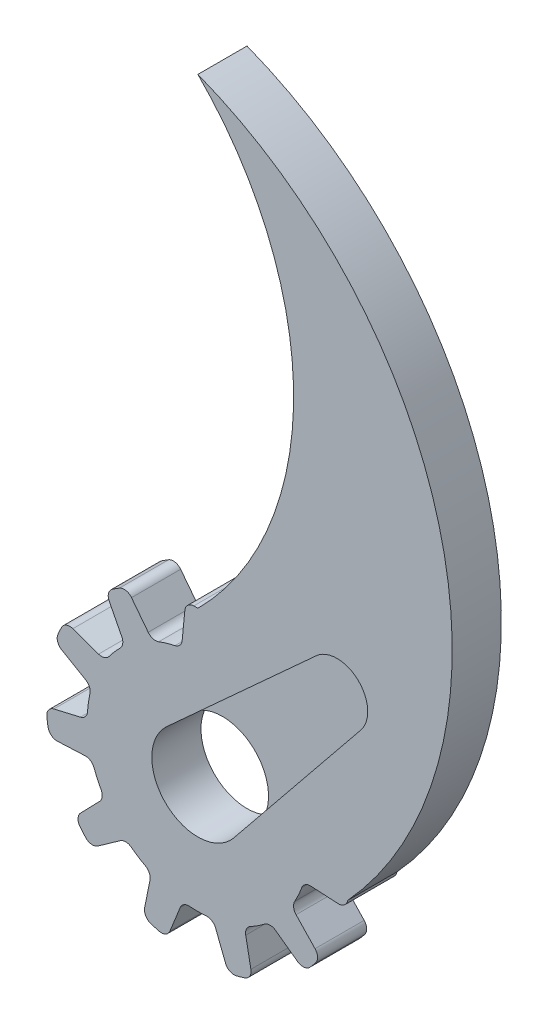
from build123d import *

# Parameters (mm, degrees)
ESBO_O1_R                = 3.75
RESSALTO_EXTRUS_O1_DEPTH = 4
RESSALTO_EXTRUS_O2_START = -4
RESSALTO_EXTRUS_O2_DEPTH = 4
CORTE_EXTRUS_O1_START    = -2
CORTE_EXTRUS_O1_DEPTH    = 2


with BuildPart() as part:
    # Esboço1 → Ressalto-extrusão1 (new body)
    with BuildSketch(Plane.XY):
        with BuildLine():
            Line((5.428931338, 10.411256864), (4.040153116, 8.653603149))
            ThreePointArc((4.040153116, 8.653603149), (3.651813796, 8.395770502), (3.186165661, 8.417146095))
            ThreePointArc((3.186165661, 8.417146095), (2.535977815, 8.635323765), (1.871064211, 8.803358377))
            ThreePointArc((1.871064211, 8.803358377), (1.465141223, 9.040151498), (1.27980553, 9.472002324))
            Line((1.27980553, 9.472002324), (1.087391415, 11.684866251))
            ThreePointArc((1.087391415, 11.684866251), (0.855086446, 12.165243662), (0.362160028, 12.369575749))
            ThreePointArc((0.362160028, 12.369575749), (0.013315066, 12.374869163), (-0.335540479, 12.370326458))
            ThreePointArc((-0.335540479, 12.370326458), (-0.826548297, 12.16926195), (-1.061642754, 11.693608494))
            Line((-1.061642754, 11.693608494), (-1.279697998, 9.464145904))
            ThreePointArc((-1.279697998, 9.464145904), (-1.466994971, 9.037291191), (-1.870279627, 8.803525096))
            ThreePointArc((-1.870279627, 8.803525096), (-2.535208203, 8.635549743), (-3.185415492, 8.41743002))
            ThreePointArc((-3.185415492, 8.41743002), (-3.654919666, 8.397174533), (-4.044310156, 8.660270526))
            Line((-4.044310156, 8.660270526), (-5.402543773, 10.417823198))
            ThreePointArc((-5.402543773, 10.417823198), (-5.857682784, 10.696348844), (-6.382829142, 10.601747792))
            ThreePointArc((-6.382829142, 10.601747792), (-6.679158034, 10.41760107), (-6.970178022, 10.225173956))
            ThreePointArc((-6.970178022, 10.225173956), (-7.274536404, 9.790568861), (-7.215152773, 9.263322051))
            Line((-7.215152773, 9.263322051), (-6.19325404, 7.269889205))
            ThreePointArc((-6.19325404, 7.269889205), (-6.120043199, 6.809535782), (-6.332924348, 6.394847082))
            ThreePointArc((-6.332924348, 6.394847082), (-6.80148353, 5.894049694), (-7.230548283, 5.359027107))
            ThreePointArc((-7.230548283, 5.359027107), (-7.614569385, 5.088153986), (-8.084385943, 5.098964027))
            Line((-8.084385943, 5.098964027), (-10.177209485, 5.843194888))
            ThreePointArc((-10.177209485, 5.843194888), (-10.710679119, 5.831438844), (-11.101315158, 5.46793982))
            ThreePointArc((-11.101315158, 5.46793982), (-11.251045651, 5.152818244), (-11.391833292, 4.833600971))
            ThreePointArc((-11.391833292, 4.833600971), (-11.412910602, 4.303439334), (-11.077902766, 3.891996308))
            Line((-11.077902766, 3.891996308), (-9.140495683, 2.76749405))
            ThreePointArc((-9.140495683, 2.76749405), (-8.830020954, 2.419800875), (-8.784910335, 1.955850303))
            ThreePointArc((-8.784910335, 1.955850303), (-8.908335893, 1.281230512), (-8.980033083, 0.599170952))
            ThreePointArc((-8.980033083, 0.599170952), (-9.156647127, 0.163680499), (-9.557726315, -0.081227523))
            Line((-9.557726315, -0.081227523), (-11.720683094, -0.586606513))
            ThreePointArc((-11.720683094, -0.586606513), (-12.163110512, -0.884911785), (-12.295212049, -1.401900411))
            ThreePointArc((-12.295212049, -1.401900411), (-12.25080577, -1.747947966), (-12.196661982, -2.09260617))
            ThreePointArc((-12.196661982, -2.09260617), (-11.927766323, -2.550001774), (-11.423496904, -2.715010763))
            Line((-11.423496904, -2.715010763), (-9.185694531, -2.613560912))
            ThreePointArc((-9.185694531, -2.613560912), (-8.736529446, -2.738203711), (-8.447749362, -3.104115127))
            ThreePointArc((-8.447749362, -3.104115127), (-8.186854553, -3.738370305), (-7.878420829, -4.350917747))
            ThreePointArc((-7.878420829, -4.350917747), (-7.791554103, -4.812760389), (-7.996556113, -5.235629909))
            Line((-7.996556113, -5.235629909), (-9.542922635, -6.83016449))
            ThreePointArc((-9.542922635, -6.83016449), (-9.753840257, -7.320309176), (-9.585465989, -7.826647167))
            ThreePointArc((-9.585465989, -7.826647167), (-9.361021617, -8.093753047), (-9.129136671, -8.354425638))
            ThreePointArc((-9.129136671, -8.354425638), (-8.655640515, -8.593835336), (-8.142211489, -8.4600211))
            Line((-8.142211489, -8.4600211), (-6.314500268, -7.16482875))
            ThreePointArc((-6.314500268, -7.16482875), (-5.869251568, -7.026847967), (-5.428487655, -7.178545938))
            ThreePointArc((-5.428487655, -7.178545938), (-4.866104738, -7.571064963), (-4.275465628, -7.919620803))
            ThreePointArc((-4.275465628, -7.919620803), (-3.952697704, -8.26118386), (-3.896535847, -8.727756791))
            Line((-3.896535847, -8.727756791), (-4.335351667, -10.905193502))
            ThreePointArc((-4.335351667, -10.905193502), (-4.247794638, -11.431560125), (-3.832402205, -11.766488747))
            ThreePointArc((-3.832402205, -11.766488747), (-3.499179242, -11.869848724), (-3.16317497, -11.963773995))
            ThreePointArc((-3.16317497, -11.963773995), (-2.635410001, -11.909186901), (-2.275831457, -11.519034514))
            Line((-2.275831457, -11.519034514), (-1.438496786, -9.441314085))
            ThreePointArc((-1.438496786, -9.441314085), (-1.138527788, -9.084517642), (-0.685719474, -8.973839134))
            ThreePointArc((-0.685719474, -8.973839134), (-0.000401051, -8.999999991), (0.684919701, -8.973900211))
            ThreePointArc((0.684919701, -8.973900211), (1.141112287, -9.086739826), (1.440607019, -9.44888256))
            Line((1.440607019, -9.44888256), (2.248662823, -11.517900629))
            ThreePointArc((2.248662823, -11.517900629), (2.606895765, -11.913371507), (3.137422201, -11.970553289))
            ThreePointArc((3.137422201, -11.970553289), (3.473627818, -11.877351299), (3.807072434, -11.774708641))
            ThreePointArc((3.807072434, -11.774708641), (4.221544568, -11.44345577), (4.313108983, -10.920835859))
            Line((4.313108983, -10.920835859), (3.894219261, -8.720248907))
            ThreePointArc((3.894219261, -8.720248907), (3.953670521, -8.257917155), (4.274759795, -7.920001811))
            ThreePointArc((4.274759795, -7.920001811), (4.865429967, -7.571498612), (5.427847864, -7.179029709))
            ThreePointArc((5.427847864, -7.179029709), (5.87262719, -7.0273201), (6.320367336, -7.170054878))
            Line((6.320367336, -7.170054878), (8.118742756, -8.473755688))
            ThreePointArc((8.118742756, -8.473755688), (8.633915182, -8.612771611), (9.111137226, -8.374051741))
            ThreePointArc((9.111137226, -8.374051741), (9.343582589, -8.113878758), (9.56860124, -7.847256489))
            ThreePointArc((9.56860124, -7.847256489), (9.738188564, -7.344508289), (9.532667795, -6.855348982))
            Line((9.532667795, -6.855348982), (7.990548209, -5.230566315))
            ThreePointArc((7.990548209, -5.230566315), (7.790606374, -4.809486318), (7.878033033, -4.351619874))
            ThreePointArc((7.878033033, -4.351619874), (8.186521347, -3.739099922), (8.447472682, -3.104867999))
            ThreePointArc((8.447472682, -3.104867999), (8.739624454, -2.736775896), (9.19345568, -2.614785434))
            Line((9.19345568, -2.614785434), (11.411179228, -2.739253189))
            ThreePointArc((11.411179228, -2.739253189), (11.919727533, -2.577677583), (12.192130558, -2.118847933))
            ThreePointArc((12.192130558, -2.118847933), (12.247015907, -1.774307042), (12.292166761, -1.428355848))
            ThreePointArc((12.292166761, -1.428355848), (12.163026498, -0.913731319), (11.725671937, -0.61333724))
            Line((11.725671937, -0.61333724), (9.549934558, -0.080215876))
            ThreePointArc((9.549934558, -0.080215876), (9.15407975, 0.165922443), (8.980086447, 0.598370627))
            ThreePointArc((8.980086447, 0.598370627), (8.908450044, 1.280436574), (8.78508461, 1.955067363))
            ThreePointArc((8.78508461, 1.955067363), (8.831852706, 2.422675318), (9.147686805, 2.77065991))
            Line((9.147686805, 2.77065991), (11.080646922, 3.864942843))
            ThreePointArc((11.080646922, 3.864942843), (11.421110614, 4.275810864), (11.402208583, 4.809075122))
            ThreePointArc((11.402208583, 4.809075122), (11.262108208, 5.128594624), (11.113056187, 5.444037682))
            ThreePointArc((11.113056187, 5.444037682), (10.726189458, 5.807148888), (10.195858089, 5.823404741))
            Line((10.195858089, 5.823404741), (8.077284162, 5.095602537))
            ThreePointArc((8.077284162, 5.095602537), (7.611197484, 5.088652), (7.231025864, 5.358382681))
            ThreePointArc((7.231025864, 5.358382681), (6.802008795, 5.893443506), (6.333494247, 6.394282651))
            ThreePointArc((6.333494247, 6.394282651), (6.120030126, 6.812944237), (6.197592003, 7.27644031))
            Line((6.197592003, 7.27644031), (7.232087511, 9.242046831))
            ThreePointArc((7.232087511, 9.242046831), (7.296371772, 9.771759573), (6.992165948, 10.210150805))
            ThreePointArc((6.992165948, 10.210150805), (6.701560727, 10.403203734), (6.405628795, 10.587987714))
            ThreePointArc((6.405628795, 10.587987714), (5.883863054, 10.684300355), (5.428931338, 10.411256864))
        make_face()
        Circle(ESBO_O1_R, mode=Mode.SUBTRACT)
    extrude(amount=RESSALTO_EXTRUS_O1_DEPTH)

    # Esboço6 → Ressalto-extrusão2 (add)
    with BuildSketch(Plane.XY.offset(4).offset(RESSALTO_EXTRUS_O2_START)):
        with BuildLine():
            Line((0, 12.37), (0, 9))
            ThreePointArc((0, 9), (6.887269468, 5.79357569), (8.867092658, -1.540995716))
            Line((8.867092658, -1.540995716), (12.192130558, -2.118847933))
            ThreePointArc((12.192130558, -2.118847933), (19.845997755, 27.157089417), (0, 50))
            ThreePointArc((0, 50), (7.793428176, 31.185), (0, 12.37))
        make_face()
    extrude(amount=RESSALTO_EXTRUS_O2_DEPTH)

    # Esboço7 → Corte-extrusão1 (cut)
    with BuildSketch(Plane.XY.offset(4).offset(CORTE_EXTRUS_O1_START)):
        with BuildLine():
            Line((-2.524504061, 2.772972998), (9.641514463, 13.848869949))
            ThreePointArc((9.641514463, 13.848869949), (13.040353105, 13.81843663), (13.267495019, 10.427059792))
            Line((13.267495019, 10.427059792), (2.914466774, -2.359742237))
            ThreePointArc((2.914466774, -2.359742237), (-2.573753902, -2.727323019), (-2.524504061, 2.772972998))
        make_face()
    extrude(amount=CORTE_EXTRUS_O1_DEPTH, mode=Mode.SUBTRACT)


solid = part.part
